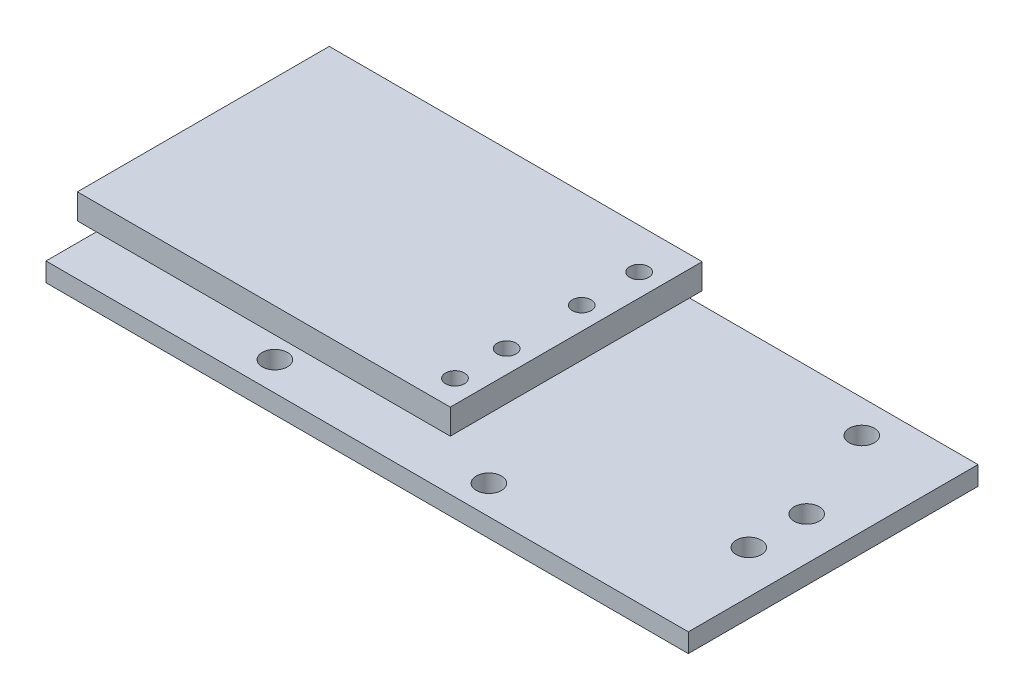
from build123d import *

# Parameters (mm, degrees)
SKETCH_1_W      = 51
SKETCH_1_H      = 23
SKETCH_1_R      = 0.5
SKETCH_1_R_2    = 1
EXTRUDE_1_DEPTH = 1.5
SKETCH_2_W      = 18.258727374
SKETCH_2_H      = 13.578190662
EXTRUDE_2_DEPTH = 2.5
SKETCH_3_W      = 29.608747094
SKETCH_3_H      = 20
SKETCH_3_R      = 0.75
EXTRUDE_3_DEPTH = 2


with BuildPart() as part:
    # Эскиз1 → Бобышка-Вытянуть1 (new body)
    with BuildSketch(Plane(origin=(0, 0, 0), x_dir=(1, 0, 0), z_dir=(0, 1, 0))):
        Rectangle(SKETCH_1_W, SKETCH_1_H)
        with Locations(Location((-18.598557526, 8.885912105, 0), (0, 0, 270))):
            Circle(SKETCH_1_R, mode=Mode.SUBTRACT)
        with Locations(Location((18.886719194, 8.885912105, 0), (0, 0, 270))):
            Circle(SKETCH_1_R_2, mode=Mode.SUBTRACT)
        with Locations(Location((22.095575567, -3.293156401, 0), (0, 0, 270))):
            Circle(SKETCH_1_R_2, mode=Mode.SUBTRACT)
        with Locations(Location((22.095575567, 1.301342497, 0), (0, 0, 270))):
            Circle(SKETCH_1_R_2, mode=Mode.SUBTRACT)
        with Locations(Location((7.364007673, -9.200369269, 0), (0, 0, 270))):
            Circle(SKETCH_1_R_2, mode=Mode.SUBTRACT)
        with Locations(Location((-9.628345393, -9.200369269, 0), (0, 0, 270))):
            Circle(SKETCH_1_R_2, mode=Mode.SUBTRACT)
    extrude(amount=EXTRUDE_1_DEPTH)

    # Эскиз2 → Бобышка-Вытянуть2 (add)
    with BuildSketch(Plane(origin=(0, 1.5, 0), x_dir=(1, 0, 0), z_dir=(0, 1, 0))):
        with Locations((-13.161113133, 0)):
            Rectangle(SKETCH_2_W, SKETCH_2_H)
    extrude(amount=EXTRUDE_2_DEPTH)

    # Эскиз3 → Бобышка-Вытянуть3 (add)
    with BuildSketch(Plane(origin=(0, 4, 0), x_dir=(1, 0, 0), z_dir=(0, 1, 0))):
        with Locations((-9.706759305, 0)):
            Rectangle(SKETCH_3_W, SKETCH_3_H)
        with Locations(Location((3.308209816, -7.836846056, 0), (0, 0, 270))):
            Circle(SKETCH_3_R, mode=Mode.SUBTRACT)
        with Locations(Location((3.308209816, -3.733593915, 0), (0, 0, 270))):
            Circle(SKETCH_3_R, mode=Mode.SUBTRACT)
        Polygon((-4.031749446, 0), (-4.031749446, -6.789095331), (-22.29047682, -6.789095331), (-22.29047682, 6.789095331), (-4.031749446, 6.789095331), align=None, mode=Mode.SUBTRACT)
        with Locations(Location((3.308209816, 2.226781891, 0), (0, 0, 270))):
            Circle(SKETCH_3_R, mode=Mode.SUBTRACT)
        with Locations(Location((3.308209816, 6.789095331, 0), (0, 0, 270))):
            Circle(SKETCH_3_R, mode=Mode.SUBTRACT)
        Polygon((-22.29047682, 6.789095331), (-13.161113133, 0), (-4.031749446, 6.789095331), align=None)
        Polygon((-22.29047682, 6.789095331), (-22.29047682, -6.789095331), (-13.161113133, 0), align=None)
        Polygon((-22.29047682, -6.789095331), (-4.031749446, -6.789095331), (-13.161113133, 0), align=None)
        Polygon((-13.161113133, 0), (-4.031749446, -6.789095331), (-4.031749446, 0), align=None)
        Polygon((-4.031749446, 6.789095331), (-13.161113133, 0), (-4.031749446, 0), align=None)
    extrude(amount=EXTRUDE_3_DEPTH)


solid = part.part
